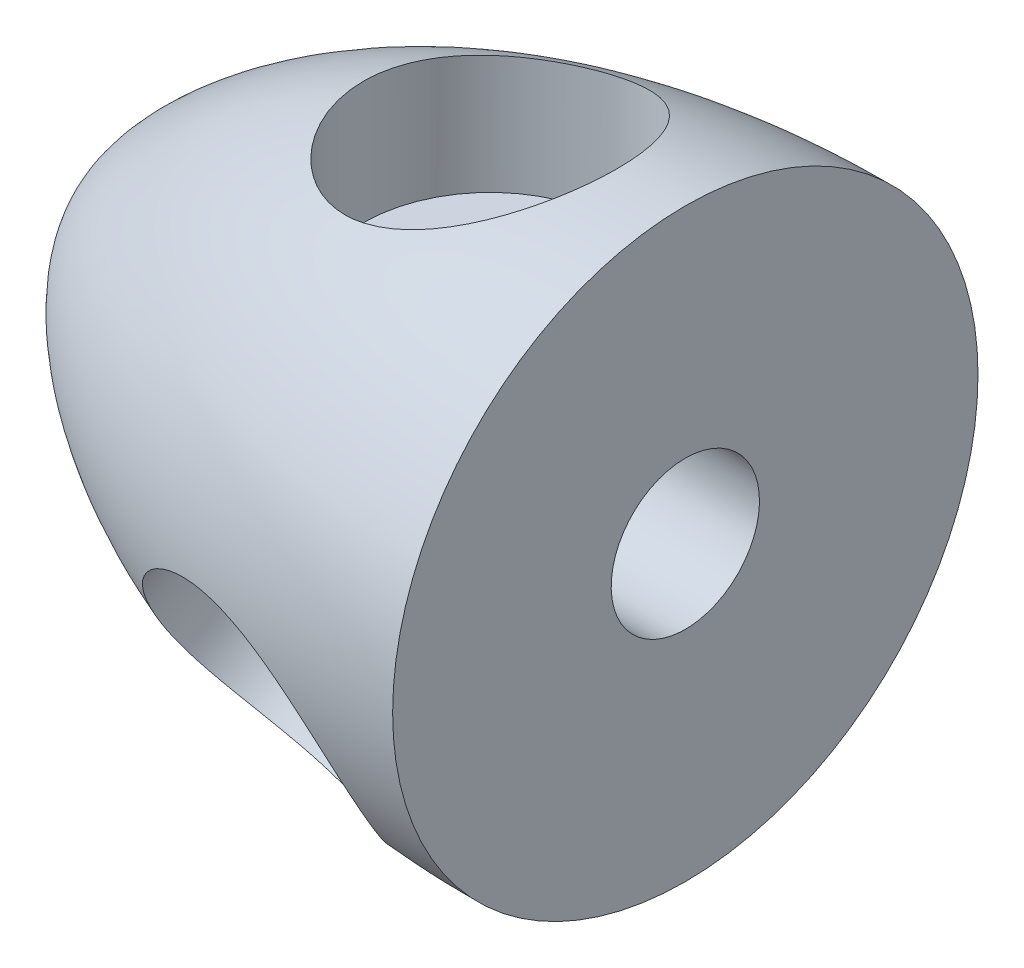
from build123d import *

# Parameters (mm, degrees)
SKETCH2_R          = 8.255
CUT_EXTRUDE1_DEPTH = 11.43
CIRPATTERN1_COUNT  = 3
SKETCH3_R          = 4.826
CUT_EXTRUDE2_DEPTH = 12.7


with BuildPart() as part:
    # Sketch1 → Revolve1 (revolve)
    with BuildSketch(Plane.XY):
        with BuildLine():
            Line((0, 19.05), (0, 0))
            Line((0, 0), (-38.1, 0))
            add(Edge.make_bspline(
                [(0, 19.05), (-25.41, 19.05), (-38.1, 6.316666667), (-38.1, 0)],
                knots=[0, 0, 0, 0, 1, 1, 1, 1], degree=3))
        make_face()
    revolve(axis=Axis((0, 0, 0), (-1, 0, 0)))

    # Sketch2 → Cut-Extrude1 (cut)
    with BuildSketch(Plane(origin=(0, 19.05, 0), x_dir=(1, 0, 0), z_dir=(0, 1, 0))):
        with Locations((-12.7, 0)):
            Circle(SKETCH2_R)
    cut_extrude1 = extrude(amount=-CUT_EXTRUDE1_DEPTH, mode=Mode.SUBTRACT)

    # CirPattern1: Cut-Extrude1 ×3 about axis
    cirpattern1_axis = Axis((0, 0, 0), (1, 0, 0))
    for i in range(1, CIRPATTERN1_COUNT):
        add(cut_extrude1.rotate(cirpattern1_axis, i * 360 / CIRPATTERN1_COUNT), mode=Mode.SUBTRACT)

    # Sketch3 → Cut-Extrude2 (cut)
    with BuildSketch(Plane(origin=(0, 0, 0), x_dir=(0, 0, -1), z_dir=(1, 0, 0))):
        Circle(SKETCH3_R)
    extrude(amount=-CUT_EXTRUDE2_DEPTH, mode=Mode.SUBTRACT)


solid = part.part
